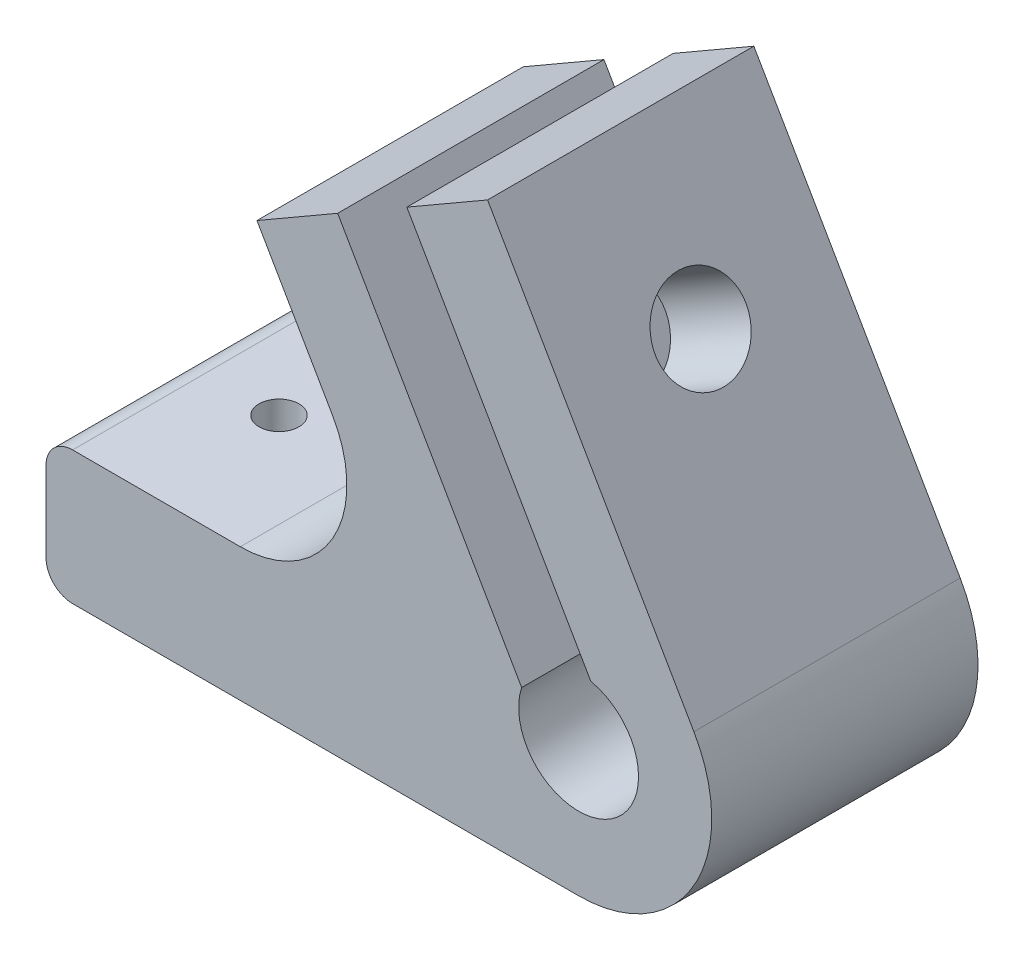
from build123d import *

# Parameters (mm, degrees)
EXTRUDE_1_DEPTH              = 10
CUT_EXTRUDE_1_DEPTH          = 906.195271262
CUT_EXTRUDE_2_REACH          = 458.977
SKETCH_4_W                   = 2.25
SKETCH_4_H                   = 10
HOLE_WIZARD_3_4_3_4_1_D      = 3.4
HOLE_WIZARD_3_4_3_4_1_DEPTH  = 3.5
HOLE_WIZARD_1_5_1_5_1_D      = 1.5
SKETCH_9_W                   = 1.7
SKETCH_9_H                   = 16.290640731
HOLE_WIZARD_1_5_1_5_2_REACH  = 907.297
HOLE_WIZARD_1_5_1_5_2_BORE_R = 0.75
FILLET_1_R                   = 1


with BuildPart() as part:
    # 草图1 → 凸台-拉伸1 (new body)
    with BuildSketch(Plane.XY.offset(10)):
        with BuildLine():
            Line((904.330127019, 2.5), (896.581493223, 15.921027424))
            Line((896.581493223, 15.921027424), (887.921239185, 10.921027424))
            Line((887.921239185, 10.921027424), (890.762395693, 6))
            ThreePointArc((890.762395693, 6), (890.762395693, 2), (887.298294078, 0))
            Line((887.298294078, 0), (880, 0))
            Line((880, 0), (880, -5))
            Line((880, -5), (900, -5))
            ThreePointArc((900, -5), (904.330127019, -2.5), (904.330127019, 2.5))
        make_face()
    extrude(amount=-EXTRUDE_1_DEPTH)

    # 草图2 → 切除-拉伸1 (cut, through all)
    with BuildSketch(Plane(origin=(0, 0, 0), x_dir=(-1, 0, 0), z_dir=(0, 0, -1))):
        with BuildLine():
            Line((-890.952328098, 12.671027424), (-893.55040431, 14.171027424))
            Line((-893.55040431, 14.171027424), (-900.460512614, 2.202368755))
            ThreePointArc((-900.460512614, 2.202368755), (-898.875, 1.948557159), (-897.862436403, 0.702368755))
            Line((-897.862436403, 0.702368755), (-890.952328098, 12.671027424))
        make_face()
    extrude(amount=-CUT_EXTRUDE_1_DEPTH, mode=Mode.SUBTRACT)

    # 草图3 → 切除-拉伸2 (cut, up to next)
    with BuildSketch(Plane(origin=(671.535898385, 387.711431703, 0), x_dir=(-0.4999999999999999, 0.8660254037844386, 0), z_dir=(0.8660254037844387, 0.49999999999999994, 0)), mode=Mode.PRIVATE) as cut_extrude_2_sk1:
        Polygon((-437.644848575, 6.65), (-440.502732408, 8.3), (-443.36061624, 6.65), (-443.36061624, 3.35), (-440.502732408, 1.7), (-437.644848575, 3.35), align=None)
    cut_extrude_2_tool1 = extrude(cut_extrude_2_sk1.sketch, amount=-CUT_EXTRUDE_2_REACH, mode=Mode.PRIVATE) & part.part
    add(cut_extrude_2_tool1.solids().sort_by_distance((891.787265, 6.224875, 5))[0], mode=Mode.SUBTRACT)

    # 草图4 → 切除-旋转1 (revolve, cut)
    with BuildSketch(Plane(origin=(0, 0, 0), x_dir=(1, 0, 0), z_dir=(0, 1, 0))):
        with Locations((901.125, -5)):
            Rectangle(SKETCH_4_W, SKETCH_4_H)
    revolve(axis=Axis((900, 0, 0), (0, 0, 1)), mode=Mode.SUBTRACT)

    # Ø3.4 (3.4) 直径孔1
    with Locations(Plane(origin=(679.330127019, 392.211431703, 0), x_dir=(0, 0, -1), z_dir=(0.8660254037844565, 0.4999999999999692, 0))):
        with Locations((-5, -440.502732408)):
            Hole(HOLE_WIZARD_3_4_3_4_1_D / 2, depth=HOLE_WIZARD_3_4_3_4_1_DEPTH)

    # Ø1.5 (1.5) 直径孔1 (through all)
    with Locations(Plane(origin=(0, 0, 0), x_dir=(1, 0, 0), z_dir=(0, 1, 0))):
        with Locations((883.75, -5)):
            Hole(HOLE_WIZARD_1_5_1_5_1_D / 2)

    # 草图9 → Ø3.4 (3.4) 直径孔2 (revolve, cut)
    with BuildSketch(Plane(origin=(891.787264589, 6.224875001, 5), x_dir=(0.49999999999991085, -0.8660254037844902, 0), z_dir=(0, 0, 1))):
        with Locations((0.85, 8.145320365)):
            Rectangle(SKETCH_9_W, SKETCH_9_H)
    revolve(axis=Axis((886.288003275, 3.049875001, 5), (0.8660254037844902, 0.4999999999999106, 0)), mode=Mode.SUBTRACT)

    # Ø1.5 (1.5) 直径孔2 bore → Ø1.5 (1.5) 直径孔2 (cut, up to next)
    with BuildSketch(Plane(origin=(0, -5, 0), x_dir=(-1, 0, 0), z_dir=(0, -1, 0)), mode=Mode.PRIVATE) as hole_wizard_1_5_1_5_2_sk1:
        with Locations((-890.25, -5)):
            Circle(HOLE_WIZARD_1_5_1_5_2_BORE_R)
    hole_wizard_1_5_1_5_2_tool1 = extrude(hole_wizard_1_5_1_5_2_sk1.sketch, amount=-HOLE_WIZARD_1_5_1_5_2_REACH, mode=Mode.PRIVATE) & part.part
    add(hole_wizard_1_5_1_5_2_tool1.solids().sort_by_distance((890.25, -5, 5))[0], mode=Mode.SUBTRACT)

    # 圆角1
    fillet_1_edges = [part.edges().sort_by_distance(p)[0] for p in [
        (880, -5, 5),
        (880, 0, 5),
    ]]
    fillet(fillet_1_edges, radius=FILLET_1_R)


solid = part.part
